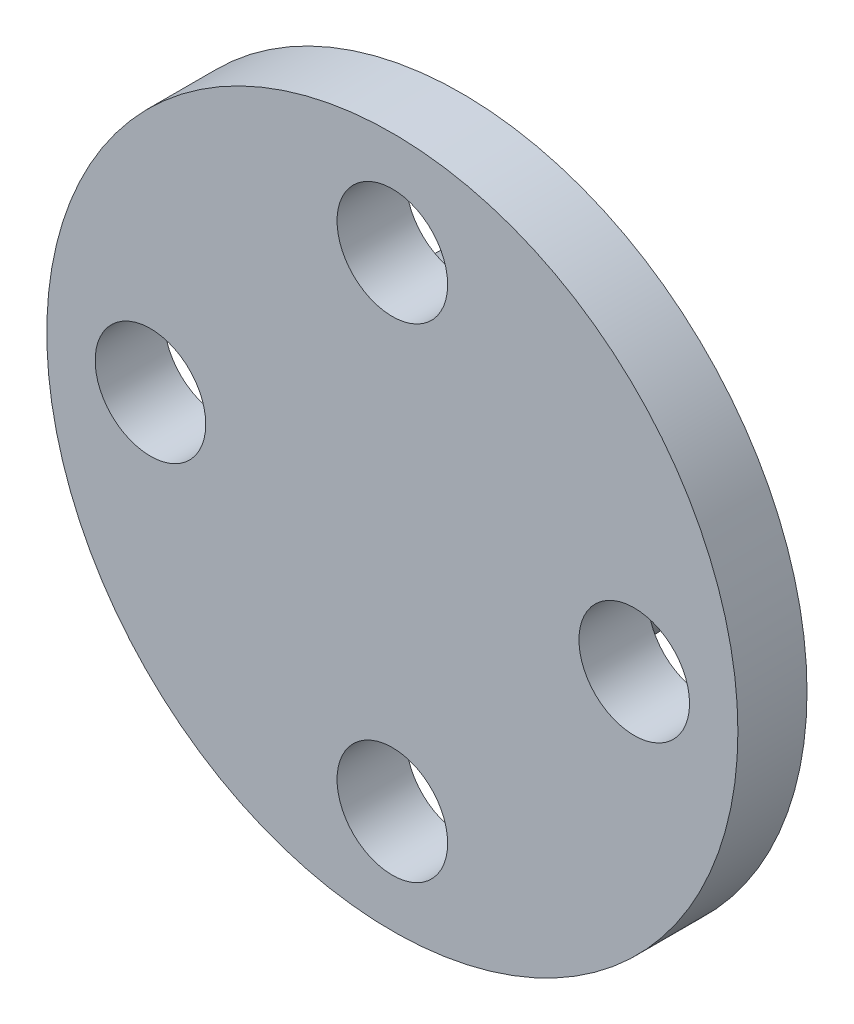
from build123d import *

# Parameters (mm, degrees)
SKETCH_1_R      = 10
SKETCH_1_R_2    = 1.6
EXTRUDE_1_DEPTH = 2
SKETCH_2_R      = 4.5
SKETCH_2_R_2    = 2.75
EXTRUDE_2_DEPTH = 2.5


with BuildPart() as part:
    # 草图1 → 凸台-拉伸1 (new body)
    with BuildSketch(Plane.XY):
        Circle(SKETCH_1_R)
        with Locations((0, 7)):
            Circle(SKETCH_1_R_2, mode=Mode.SUBTRACT)
        with Locations((7, 0)):
            Circle(SKETCH_1_R_2, mode=Mode.SUBTRACT)
        with Locations((0, -7)):
            Circle(SKETCH_1_R_2, mode=Mode.SUBTRACT)
        with Locations((-7, 0)):
            Circle(SKETCH_1_R_2, mode=Mode.SUBTRACT)
    extrude(amount=EXTRUDE_1_DEPTH)

    # 草图2 → 凸台-拉伸2 (add)
    with BuildSketch(Plane(origin=(0, 0, 0), x_dir=(-1, 0, 0), z_dir=(0, 0, -1))):
        Circle(SKETCH_2_R)
        Circle(SKETCH_2_R_2, mode=Mode.SUBTRACT)
    extrude(amount=EXTRUDE_2_DEPTH)


solid = part.part
